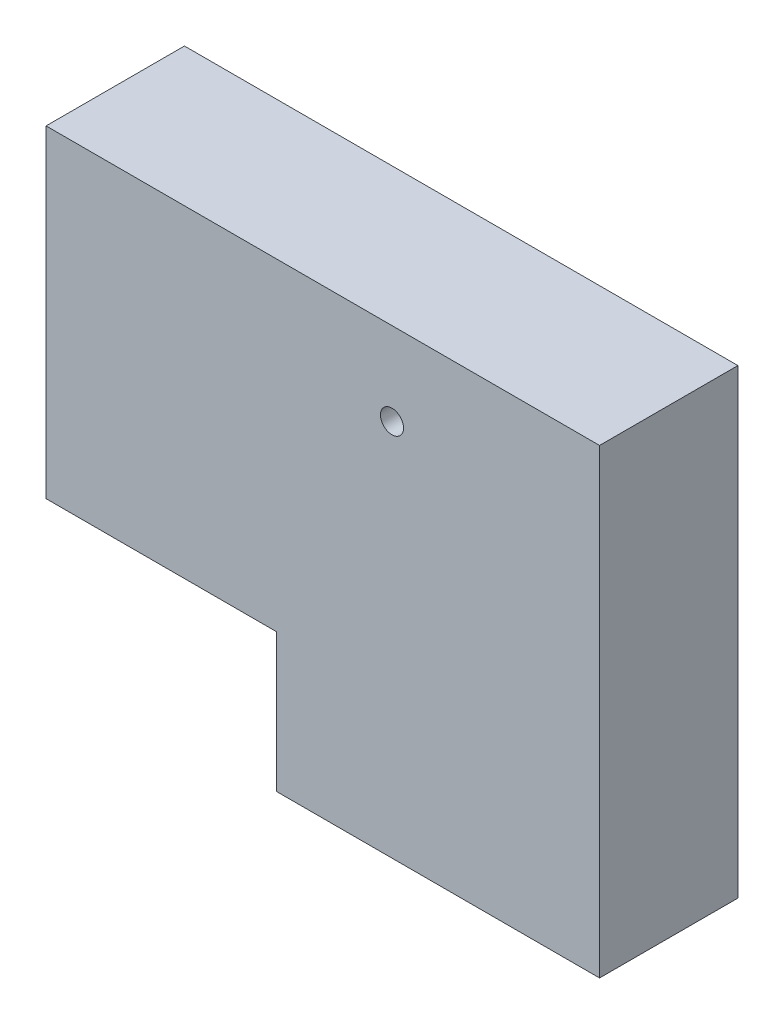
from build123d import *

# Parameters (mm, degrees)
AUFSATZ_LINEAR_AUSTRAGEN1_DEPTH = 30
M6X1_0_GEWINDEBOHRUNG1_D        = 5
M6X1_0_GEWINDEBOHRUNG1_DEPTH    = 9
M6X1_0_GEWINDEBOHRUNG1_TIP      = 1.502151548


with BuildPart() as part:
    # Skizze1 → Aufsatz-Linear austragen1 (new body)
    with BuildSketch(Plane.XY):
        Polygon((-120, -70), (-70, -70), (-70, -100), (0, -100), (0, 0), (-120, 0), align=None)
    extrude(amount=AUFSATZ_LINEAR_AUSTRAGEN1_DEPTH)

    # M6x1.0 Gewindebohrung1
    with Locations(Plane.XY.offset(30)):
        with Locations((-45, -18)):
            Hole(M6X1_0_GEWINDEBOHRUNG1_D / 2, depth=M6X1_0_GEWINDEBOHRUNG1_DEPTH)
            with Locations((0, 0, -(M6X1_0_GEWINDEBOHRUNG1_DEPTH + M6X1_0_GEWINDEBOHRUNG1_TIP / 2))):  # 118° drill point
                Cone(0, M6X1_0_GEWINDEBOHRUNG1_D / 2, M6X1_0_GEWINDEBOHRUNG1_TIP, mode=Mode.SUBTRACT)


solid = part.part
